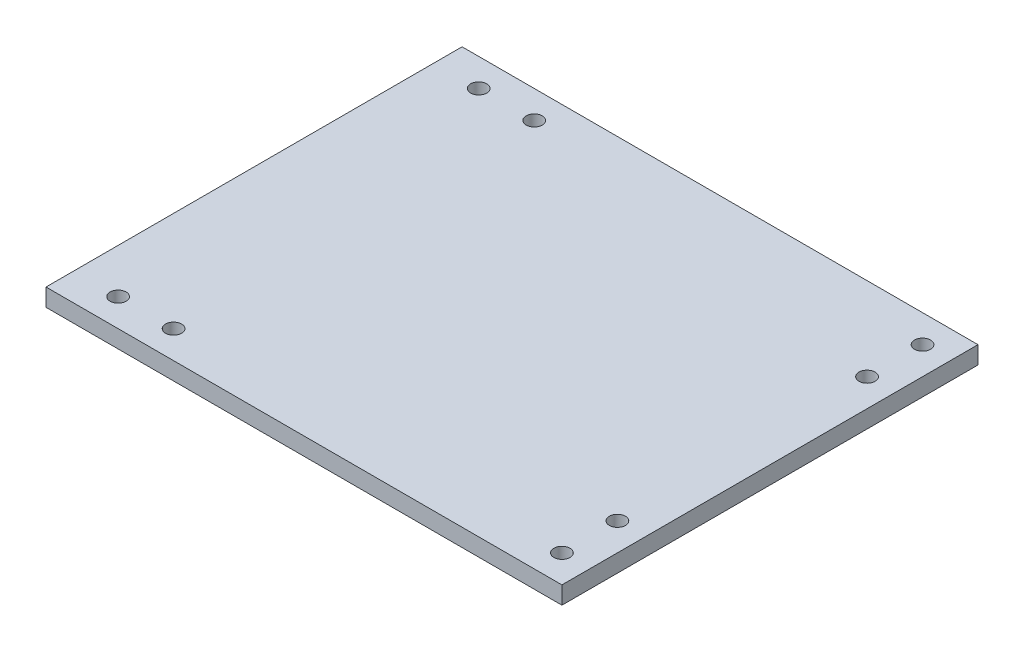
from build123d import *

# Parameters (mm, degrees)
SKETCH1_W           = 93
SKETCH1_H           = 37.5
SKETCH1_R           = 1.45
BOSS_EXTRUDE1_DEPTH = 3.175


with BuildPart() as part:
    # Sketch1 → Boss-Extrude1 (new body)
    with BuildSketch(Plane(origin=(0, 0, 0), x_dir=(1, 0, 0), z_dir=(0, 1, 0))):
        with Locations((43.5, -18.75)):
            Rectangle(SKETCH1_W, SKETCH1_H)
        with Locations((85, -32.5)):
            Circle(SKETCH1_R, mode=Mode.SUBTRACT)
        with Locations((85, -22.5)):
            Circle(SKETCH1_R, mode=Mode.SUBTRACT)
        with Locations((5, -32.5)):
            Circle(SKETCH1_R, mode=Mode.SUBTRACT)
        with Locations((15, -32.5)):
            Circle(SKETCH1_R, mode=Mode.SUBTRACT)
    boss_extrude1 = extrude(amount=BOSS_EXTRUDE1_DEPTH)

    # Mirror1: Boss-Extrude1 across plane
    add(boss_extrude1.mirror(Plane(origin=(-3, 3.175, 0), x_dir=(1, 0, 0), z_dir=(0, 0, 1))))


solid = part.part
